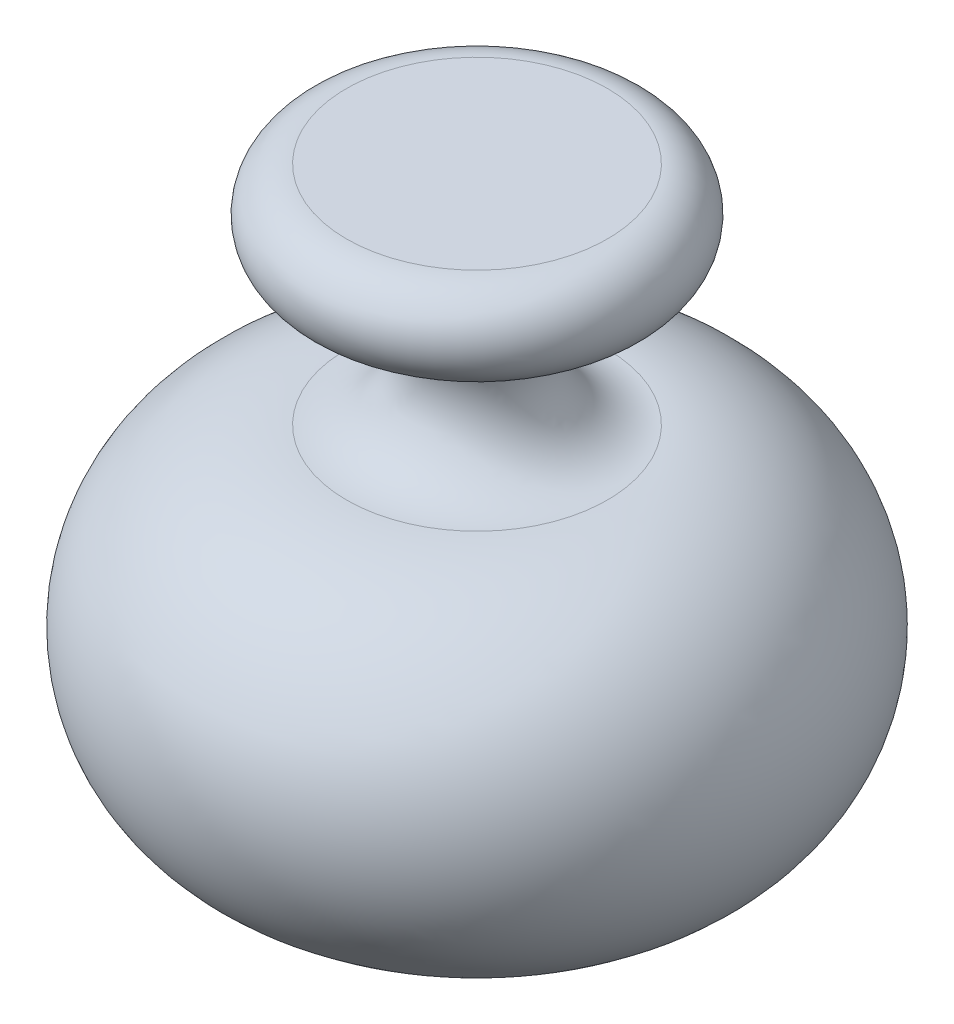
from build123d import *


with BuildPart() as part:
    # Skica1 → Rotovat1 (revolve)
    with BuildSketch(Plane.XY):
        with BuildLine():
            Line((0, 0), (15, 0))
            ThreePointArc((15, 0), (35, 20), (15, 40))
            ThreePointArc((15, 40), (7, 48), (15, 56))
            ThreePointArc((15, 56), (20, 61), (15, 66))
            Line((15, 66), (0, 66))
            Line((0, 66), (0, 0))
        make_face()
    revolve(axis=Axis((0, 66, 0), (0, -1, 0)))


solid = part.part
